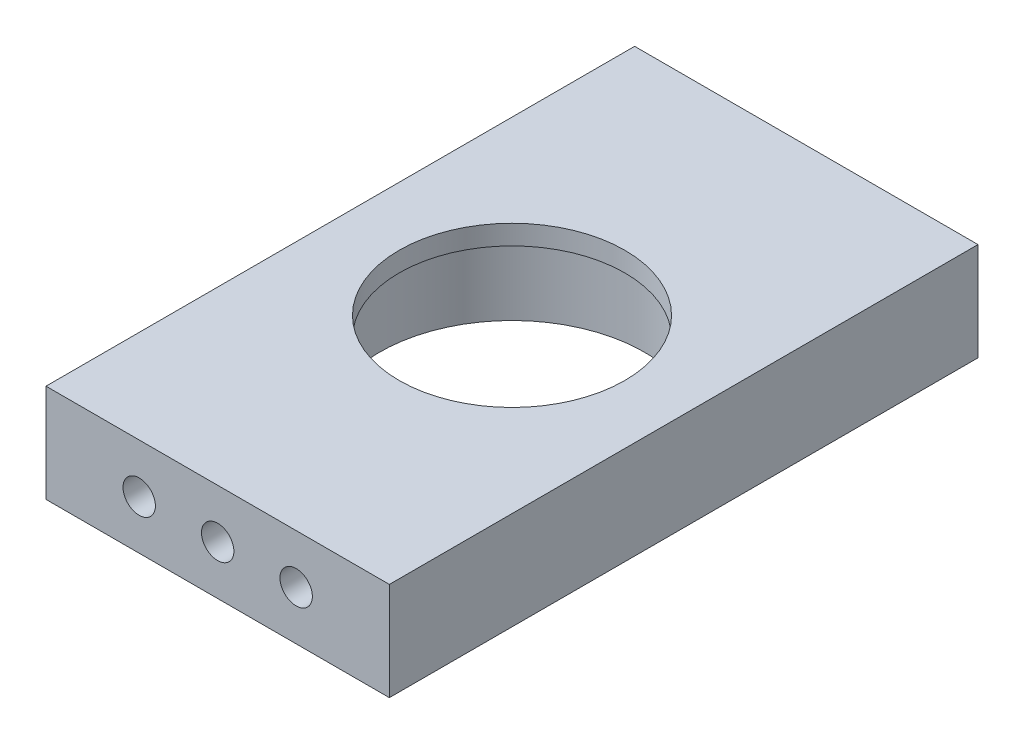
from build123d import *

# Parameters (mm, degrees)
SKETCH_1_W             = 35
SKETCH_1_H             = 60
SKETCH_1_R             = 13.5
EXTRUDE_1_DEPTH        = 10
SKETCH_3_R             = 13.5
SKETCH_3_R_2           = 11.5
EXTRUDE_2_DEPTH        = 2
HOLE_WIZARD_M4_2_D     = 3.3
HOLE_WIZARD_M4_2_DEPTH = 11.5
HOLE_WIZARD_M4_2_TIP   = 0.991420021
HOLE_WIZARD_M4_3_D     = 3.3
HOLE_WIZARD_M4_3_DEPTH = 11.5
HOLE_WIZARD_M4_3_TIP   = 0.991420021


with BuildPart() as part:
    # 스케치1 → 보스-돌출1 (new body)
    with BuildSketch(Plane(origin=(0, 0, 0), x_dir=(1, 0, 0), z_dir=(0, 1, 0))):
        Rectangle(SKETCH_1_W, SKETCH_1_H)
        Circle(SKETCH_1_R, mode=Mode.SUBTRACT)
    extrude(amount=EXTRUDE_1_DEPTH)

    # 스케치3 → 보스-돌출2 (add)
    with BuildSketch(Plane(origin=(0, 10, 0), x_dir=(1, 0, 0), z_dir=(0, 1, 0))):
        Circle(SKETCH_3_R)
        Circle(SKETCH_3_R_2, mode=Mode.SUBTRACT)
    extrude(amount=-EXTRUDE_2_DEPTH)

    # M4 나사 구멍2
    with Locations(Plane.XY.offset(30)):
        with Locations((-8, 5), (0, 5), (8, 5)):
            Hole(HOLE_WIZARD_M4_2_D / 2, depth=HOLE_WIZARD_M4_2_DEPTH)
            with Locations((0, 0, -(HOLE_WIZARD_M4_2_DEPTH + HOLE_WIZARD_M4_2_TIP / 2))):  # 118° drill point
                Cone(0, HOLE_WIZARD_M4_2_D / 2, HOLE_WIZARD_M4_2_TIP, mode=Mode.SUBTRACT)

    # M4 나사 구멍3
    with Locations(Plane(origin=(0, 0, -30), x_dir=(-1, 0, 0), z_dir=(0, 0, -1))):
        with Locations((-8, 5), (0, 5), (8, 5)):
            Hole(HOLE_WIZARD_M4_3_D / 2, depth=HOLE_WIZARD_M4_3_DEPTH)
            with Locations((0, 0, -(HOLE_WIZARD_M4_3_DEPTH + HOLE_WIZARD_M4_3_TIP / 2))):  # 118° drill point
                Cone(0, HOLE_WIZARD_M4_3_D / 2, HOLE_WIZARD_M4_3_TIP, mode=Mode.SUBTRACT)


solid = part.part
